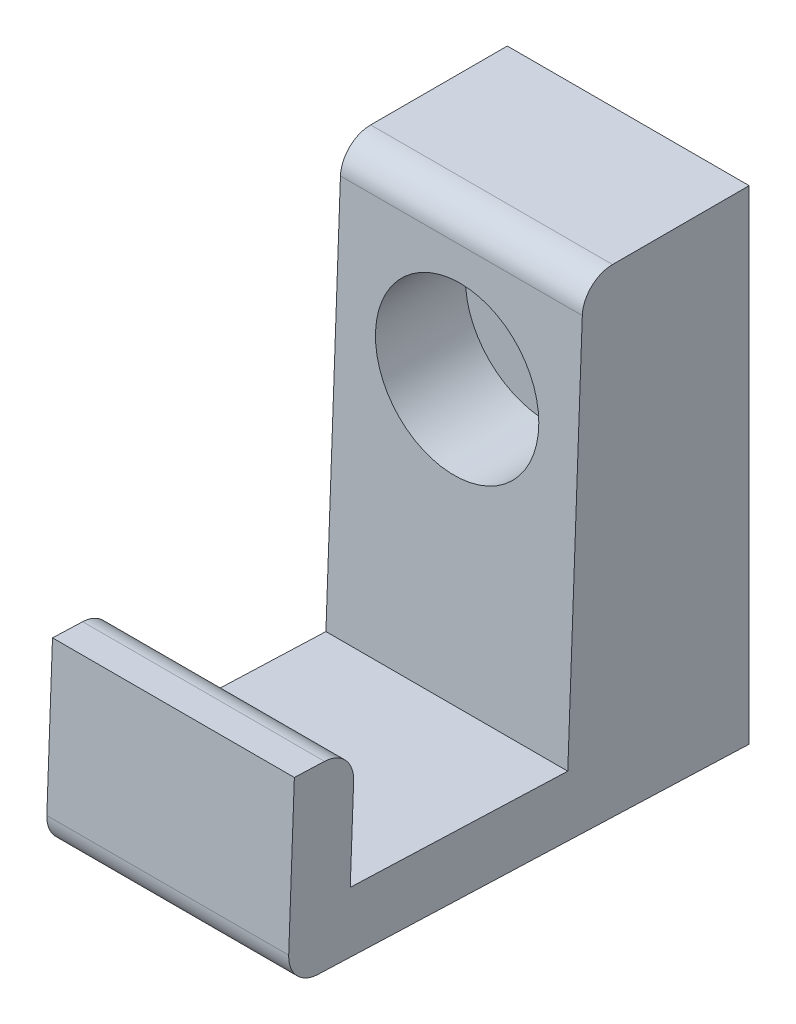
from build123d import *

# Parameters (mm, degrees)
BOSS_EXTRUDE1_DEPTH            = 10
SKETCH5_R                      = 6.75
CUT_EXTRUDE1_DEPTH             = 7
CUT_EXTRUDE1_DIRECTION_2_REACH = 26.463
CUT_EXTRUDE2_REACH             = 8.708
SKETCH6_R                      = 2.5
FILLET1_R                      = 2.5


with BuildPart() as part:
    # Sketch4 → Boss-Extrude1 (new body, symmetric)
    with BuildSketch(Plane(origin=(0, 0, 0), x_dir=(0, 0, -1), z_dir=(1, 0, 0))):
        Polygon((0, 0), (0, 40), (-13.707990749, 40), (-15, 5.56634393), (-32.987342463, 6.241259565), (-32.612389332, 16.2342276), (-37.60887335, 16.421704166), (-38.171303046, 1.432252113), align=None)
    extrude(amount=BOSS_EXTRUDE1_DEPTH, both=True)

    # Sketch5 → Cut-Extrude1 (cut)
    with BuildSketch(Plane.XY.offset(13.707990749)):
        with Locations((0, 28.210852083)):
            Circle(SKETCH5_R)
    extrude(amount=-CUT_EXTRUDE1_DEPTH, mode=Mode.SUBTRACT)

    # Sketch5 → Cut-Extrude1 direction 2 (cut, up to next)
    with BuildSketch(Plane.XY.offset(13.707990749), mode=Mode.PRIVATE) as cut_extrude1_direction_2_sk1:
        with Locations((0, 28.210852083)):
            Circle(SKETCH5_R)
    cut_extrude1_direction_2_tool1 = extrude(cut_extrude1_direction_2_sk1.sketch, amount=CUT_EXTRUDE1_DIRECTION_2_REACH, mode=Mode.PRIVATE) & part.part
    add(cut_extrude1_direction_2_tool1.solids().sort_by_distance((0, 28.210852, 13.707991))[0], mode=Mode.SUBTRACT)

    # Sketch6 → Cut-Extrude2 (cut, up to next)
    with BuildSketch(Plane.XY.offset(6.707990749), mode=Mode.PRIVATE) as cut_extrude2_sk1:
        with Locations((0, 28.210852083)):
            Circle(SKETCH6_R)
    cut_extrude2_tool1 = extrude(cut_extrude2_sk1.sketch, amount=-CUT_EXTRUDE2_REACH, mode=Mode.PRIVATE) & part.part
    add(cut_extrude2_tool1.solids().sort_by_distance((0, 28.210852, 6.707991))[0], mode=Mode.SUBTRACT)

    # Fillet1
    fillet1_edges = [part.edges().sort_by_distance(p)[0] for p in [
        (0, 1.432252113, 38.171303046),
        (0, 16.2342276, 32.612389332),
        (0, 40, 13.707990749),
    ]]
    fillet(fillet1_edges, radius=FILLET1_R)


solid = part.part
